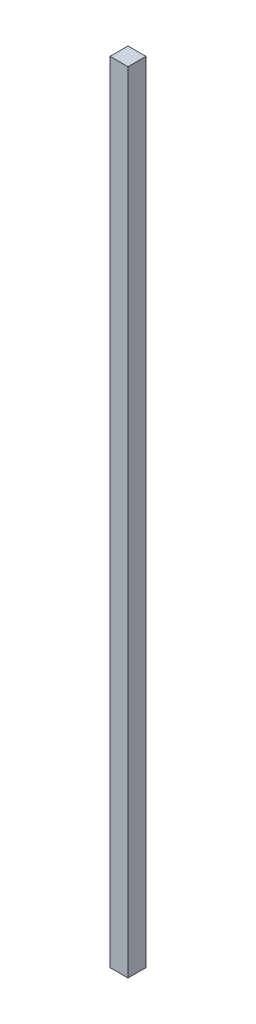
from build123d import *

# Parameters (mm, degrees)
SKETCH_1_W      = 5
SKETCH_1_H      = 220
EXTRUDE_1_DEPTH = 5


with BuildPart() as part:
    # 草图1 → 凸台-拉伸1 (new body)
    with BuildSketch(Plane.XY):
        Rectangle(SKETCH_1_W, SKETCH_1_H)
    extrude(amount=EXTRUDE_1_DEPTH)


solid = part.part
